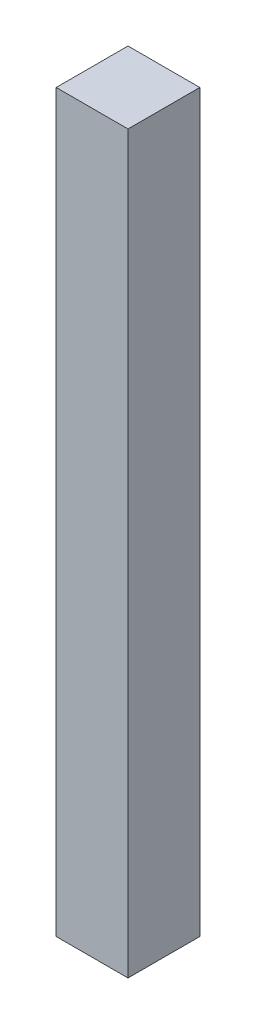
from build123d import *

# Parameters (mm, degrees)
SKETCH1_W           = 6.3
SKETCH1_H           = 6.3
BOSS_EXTRUDE1_DEPTH = 64.5


with BuildPart() as part:
    # Sketch1 → Boss-Extrude1 (new body)
    with BuildSketch(Plane(origin=(0, 0, 0), x_dir=(1, 0, 0), z_dir=(0, 1, 0))):
        Rectangle(SKETCH1_W, SKETCH1_H)
    extrude(amount=BOSS_EXTRUDE1_DEPTH)


solid = part.part
